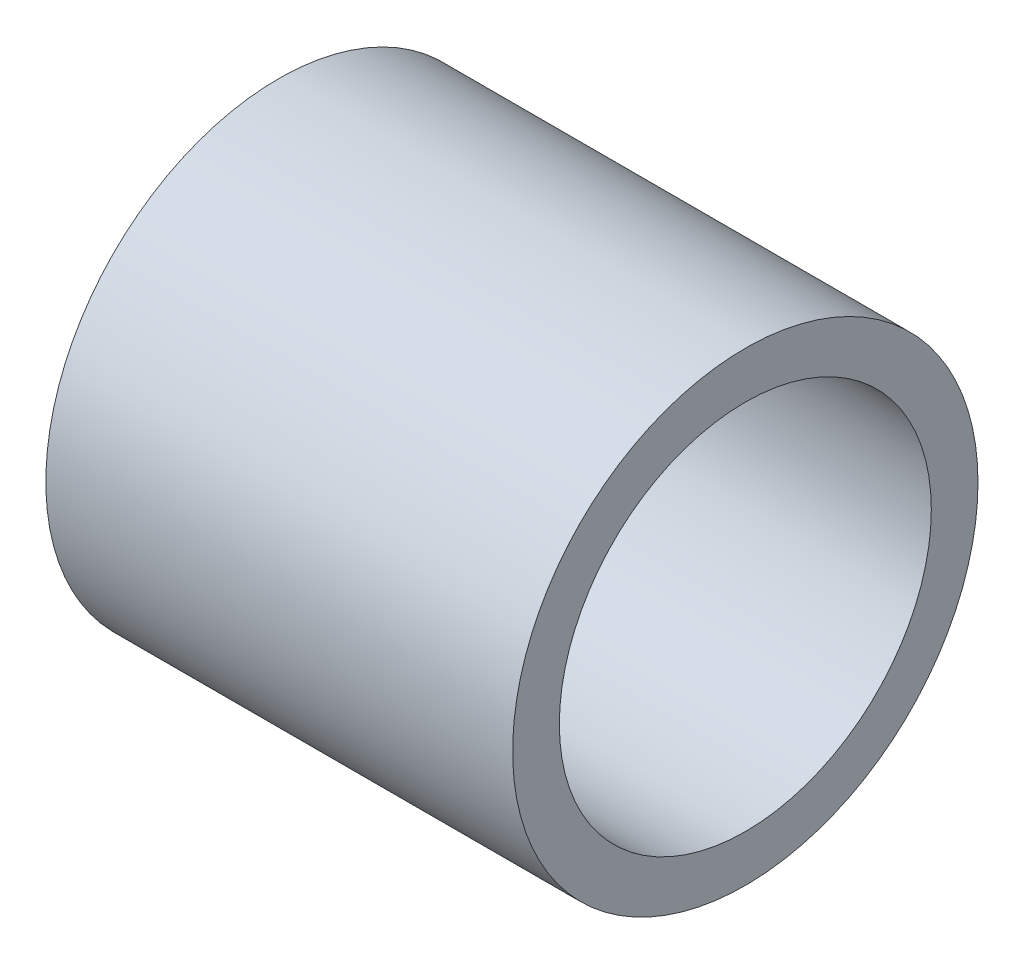
from build123d import *

# Parameters (mm, degrees)
SKETCH1_R           = 15.825
SKETCH1_R_2         = 12.65
BOSS_EXTRUDE1_DEPTH = 31.75


with BuildPart() as part:
    # Sketch1 → Boss-Extrude1 (new body)
    with BuildSketch(Plane(origin=(0, 0, 0), x_dir=(0, 0, -1), z_dir=(1, 0, 0))):
        Circle(SKETCH1_R)
        Circle(SKETCH1_R_2, mode=Mode.SUBTRACT)
    extrude(amount=BOSS_EXTRUDE1_DEPTH)


solid = part.part
